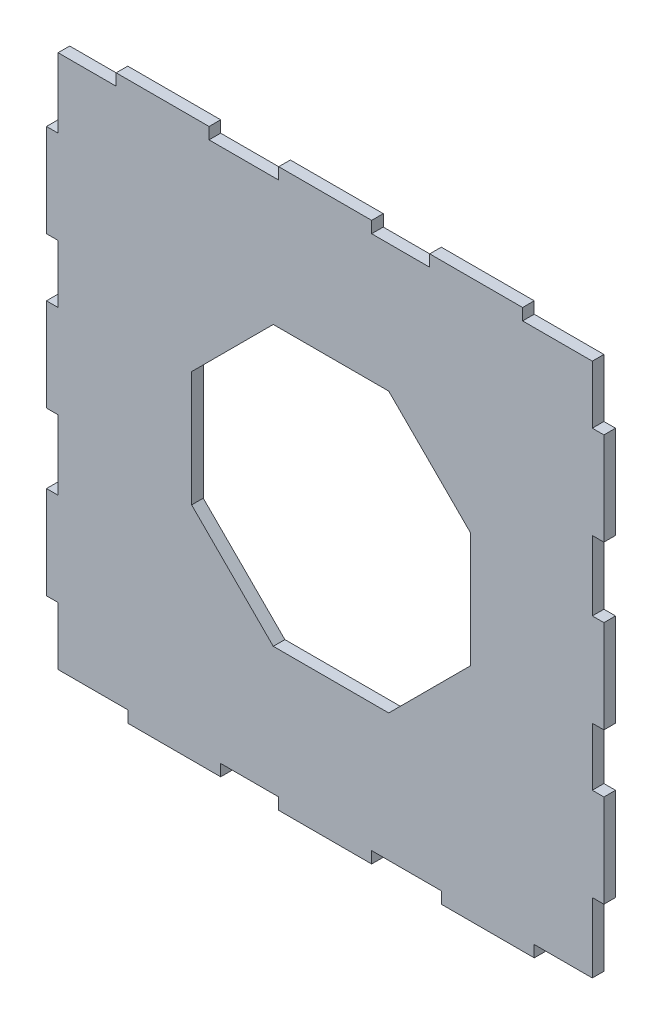
from build123d import *

# Parameters (mm, degrees)
BOSS_EXTRUDE1_DEPTH = 3.175
CUT_EXTRUDE1_DEPTH  = 4.175


with BuildPart() as part:
    # Sketch1 → Boss-Extrude1 (new body)
    with BuildSketch(Plane.XY):
        Polygon((-33.3375, 149.225), (-58.7375, 149.225), (-58.7375, 146.05), (-74.6125, 146.05), (-74.6125, 127), (-77.7875, 127), (-77.7875, 101.6), (-74.6125, 101.6), (-74.6125, 85.725), (-77.7875, 85.725), (-77.7875, 60.325), (-74.6125, 60.325), (-74.6125, 41.275), (-77.7875, 41.275), (-77.7875, 15.875), (-74.6125, 15.875), (-74.6125, 0), (-55.5625, 0), (-55.5625, -3.175), (-30.1625, -3.175), (-30.1625, 0), (-14.2875, 0), (-14.2875, -3.175), (11.1125, -3.175), (11.1125, 0), (30.1625, 0), (30.1625, -3.175), (55.5625, -3.175), (55.5625, 0), (71.4375, 0), (71.4375, 19.05), (74.6125, 19.05), (74.6125, 44.45), (71.4375, 44.45), (71.4375, 60.325), (74.6125, 60.325), (74.6125, 85.725), (71.4375, 85.725), (71.4375, 104.775), (74.6125, 104.775), (74.6125, 130.175), (71.4375, 130.175), (71.4375, 146.05), (52.3875, 146.05), (52.3875, 149.225), (26.9875, 149.225), (26.9875, 146.05), (11.1125, 146.05), (11.1125, 149.225), (-14.2875, 149.225), (-14.2875, 146.05), (-33.3375, 146.05), align=None)
    extrude(amount=BOSS_EXTRUDE1_DEPTH)

    # Sketch2 → Cut-Extrude1 (cut, through all)
    with BuildSketch(Plane.XY.offset(3.175)):
        Polygon((-38.1, 73.025), (0, 73.025), (0, 111.125), (-15.781536726, 111.125), (-38.1, 88.806536726), align=None)
        Polygon((0, 111.125), (0, 73.025), (38.1, 73.025), (38.1, 88.806536726), (15.781536726, 111.125), align=None)
        Polygon((0, 73.025), (0, 34.925), (15.781536726, 34.925), (38.1, 57.243463274), (38.1, 73.025), align=None)
        Polygon((-15.781536726, 34.925), (0, 34.925), (0, 73.025), (-38.1, 73.025), (-38.1, 57.243463274), align=None)
    extrude(amount=-CUT_EXTRUDE1_DEPTH, mode=Mode.SUBTRACT)


solid = part.part
